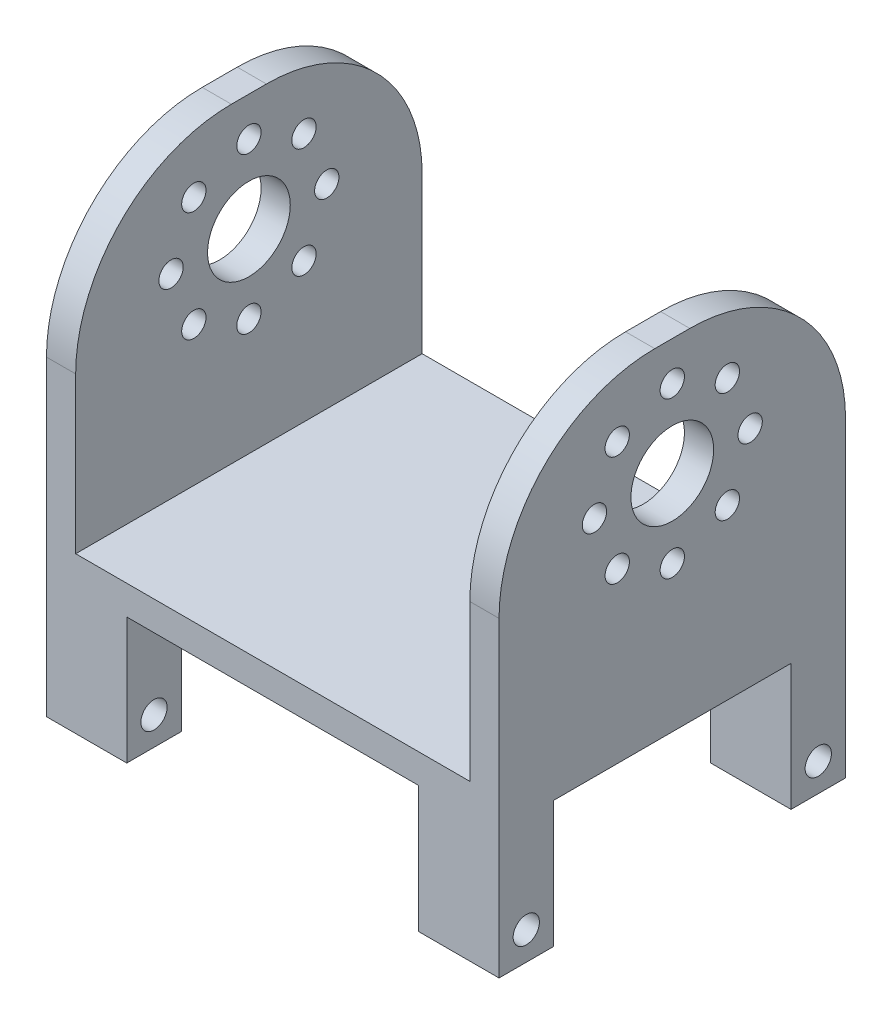
from build123d import *

# Parameters (mm, degrees)
SKETCH1_W                = 46.5
SKETCH1_H                = 35.6
BOSS_EXTRUDE1_DEPTH      = 2
SKETCH2_W                = 3
SKETCH2_H                = 35.6
BOSS_EXTRUDE2_DEPTH      = 50
SKETCH3_R                = 4.25
CUT_EXTRUDE1_DEPTH       = 47.5
SKETCH6_R                = 1.25
CUT_EXTRUDE3_DEPTH       = 47.5
FILLET5_R                = 16
SKETCH1_2_W              = 46.5
SKETCH1_2_H              = 35.6
CUT_EXTRUDE6_DEPTH       = 20
SKETCH8_W                = 46.5
SKETCH8_H                = 35.6
BOSS_EXTRUDE3_DEPTH      = 3
SKETCH9_W                = 35.6
SKETCH9_H                = 13
BOSS_EXTRUDE4_DEPTH      = 46.5
SKETCH12_W               = 30
SKETCH12_H               = 13
CUT_EXTRUDE9_DEPTH       = 36.6
SKETCH13_W               = 24.4
SKETCH13_H               = 13
CUT_EXTRUDE10_DEPTH      = 39.25
CUT_EXTRUDE10_DEPTH_BACK = 9.25
SKETCH15_R               = 1.35
CUT_EXTRUDE11_DEPTH      = 47.5


with BuildPart() as part:
    # Sketch1 → Boss-Extrude1 (new body)
    with BuildSketch(Plane(origin=(0, 0, 0), x_dir=(1, 0, 0), z_dir=(0, 1, 0))):
        Rectangle(SKETCH1_W, SKETCH1_H)
    extrude(amount=BOSS_EXTRUDE1_DEPTH)

    # Sketch2 → Boss-Extrude2 (add)
    with BuildSketch(Plane(origin=(0, 2, 0), x_dir=(1, 0, 0), z_dir=(0, 1, 0))):
        with Locations((-21.75, 0)):
            Rectangle(SKETCH2_W, SKETCH2_H)
        with Locations((21.75, 0)):
            Rectangle(SKETCH2_W, SKETCH2_H)
    extrude(amount=BOSS_EXTRUDE2_DEPTH)

    # Sketch3 → Cut-Extrude1 (cut, through all)
    with BuildSketch(Plane(origin=(23.25, 0, 0), x_dir=(0, 0, -1), z_dir=(1, 0, 0))):
        with Locations((0, 40)):
            Circle(SKETCH3_R)
    extrude(amount=-CUT_EXTRUDE1_DEPTH, mode=Mode.SUBTRACT)

    # Sketch6 → Cut-Extrude3 (cut, through all)
    with BuildSketch(Plane(origin=(23.25, 0, 0), x_dir=(0, 0, -1), z_dir=(1, 0, 0))):
        with Locations((0, 32)):
            Circle(SKETCH6_R)
        with Locations((-5.656854249, 34.343145751)):
            Circle(SKETCH6_R)
        with Locations((-8, 40)):
            Circle(SKETCH6_R)
        with Locations((-5.656854249, 45.656854249)):
            Circle(SKETCH6_R)
        with Locations((0, 48)):
            Circle(SKETCH6_R)
        with Locations((5.656854249, 45.656854249)):
            Circle(SKETCH6_R)
        with Locations((8, 40)):
            Circle(SKETCH6_R)
        with Locations((5.656854249, 34.343145751)):
            Circle(SKETCH6_R)
    extrude(amount=-CUT_EXTRUDE3_DEPTH, mode=Mode.SUBTRACT)

    # Fillet5
    fillet5_edges = [part.edges().sort_by_distance(p)[0] for p in [
        (-21.75, 52, 17.8),
        (-21.75, 52, -17.8),
        (21.75, 52, -17.8),
        (21.75, 52, 17.8),
    ]]
    fillet(fillet5_edges, radius=FILLET5_R)

    # Sketch1_2 → Cut-Extrude6 (cut)
    with BuildSketch(Plane(origin=(0, 0, 0), x_dir=(1, 0, 0), z_dir=(0, 1, 0))):
        Rectangle(SKETCH1_2_W, SKETCH1_2_H)
    extrude(amount=CUT_EXTRUDE6_DEPTH, mode=Mode.SUBTRACT)

    # Sketch8 → Boss-Extrude3 (add)
    with BuildSketch(Plane.XZ.offset(-20)):
        Rectangle(SKETCH8_W, SKETCH8_H)
    extrude(amount=BOSS_EXTRUDE3_DEPTH)

    # Sketch9 → Boss-Extrude4 (add)
    with BuildSketch(Plane(origin=(23.25, 0, 0), x_dir=(0, 0, -1), z_dir=(1, 0, 0))):
        with Locations((0, 10.5)):
            Rectangle(SKETCH9_W, SKETCH9_H)
    extrude(amount=-BOSS_EXTRUDE4_DEPTH)

    # Sketch12 → Cut-Extrude9 (cut, through all)
    with BuildSketch(Plane(origin=(0, 0, -17.8), x_dir=(-1, 0, 0), z_dir=(0, 0, -1))):
        with Locations((0, 10.5)):
            Rectangle(SKETCH12_W, SKETCH12_H)
    extrude(amount=-CUT_EXTRUDE9_DEPTH, mode=Mode.SUBTRACT)

    # Sketch13 → Cut-Extrude10 (cut, two sides)
    with BuildSketch(Plane.ZY.offset(-15)) as cut_extrude10_sk:
        with Locations((0, 10.5)):
            Rectangle(SKETCH13_W, SKETCH13_H)
    extrude(amount=CUT_EXTRUDE10_DEPTH, mode=Mode.SUBTRACT)
    extrude(cut_extrude10_sk.sketch, amount=-CUT_EXTRUDE10_DEPTH_BACK, mode=Mode.SUBTRACT)

    # Sketch15 → Cut-Extrude11 (cut, through all)
    with BuildSketch(Plane.ZY.offset(23.25)):
        with Locations((-15, 6.9)):
            Circle(SKETCH15_R)
        with Locations((15, 6.9)):
            Circle(SKETCH15_R)
    extrude(amount=-CUT_EXTRUDE11_DEPTH, mode=Mode.SUBTRACT)


solid = part.part
